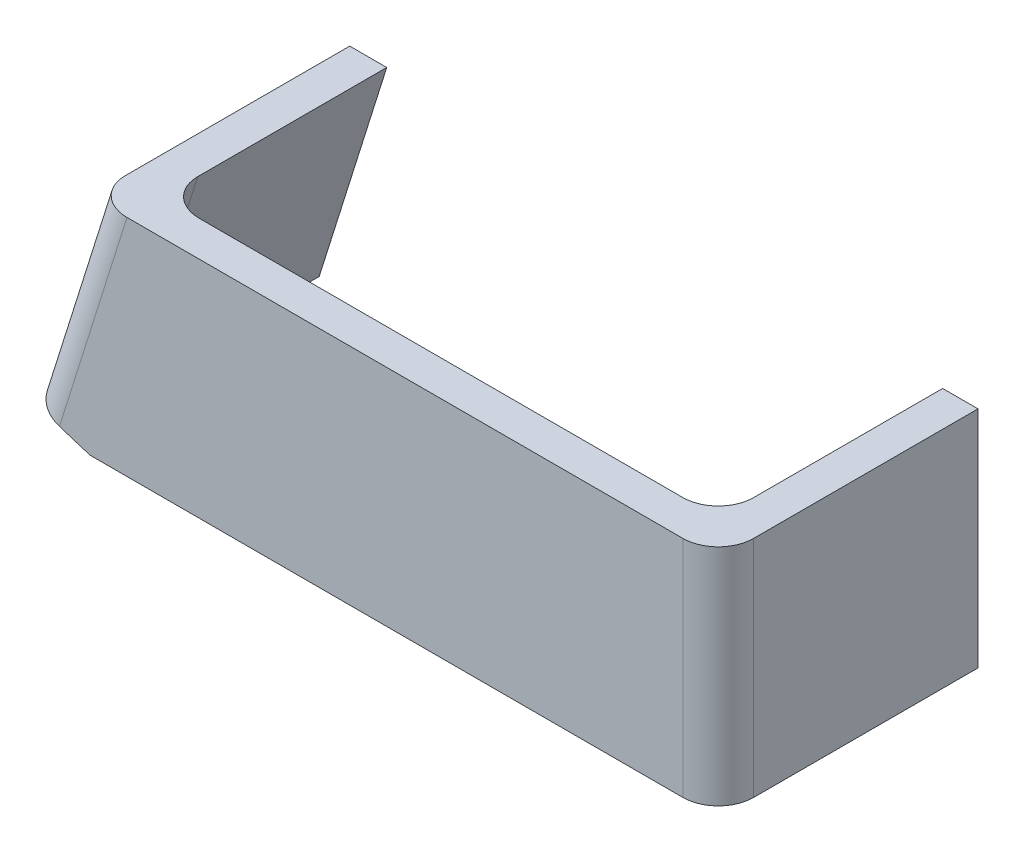
from build123d import *

# Parameters (mm, degrees)
BOSS_EXTRUDE1_DEPTH = 5
BOSS_EXTRUDE2_DEPTH = 31.75
FILLET1_R           = 5


with BuildPart() as part:
    # Sketch1 → Boss-Extrude1 (new body)
    with BuildSketch(Plane.XY):
        Polygon((-44.432958232964275, 15.875000000000018), (44.46704176703572, 15.875000000000021), (44.467041767035624, -15.874999999999979), (-44.43295823296417, -15.875000000000448), (-53.51922912646058, -13.017500000000476), align=None)
    extrude(amount=BOSS_EXTRUDE1_DEPTH)

    # Sketch2 → Boss-Extrude2 (add)
    with BuildSketch(Plane(origin=(0, 0, 0), x_dir=(-1, 0, 0), z_dir=(0, 0, -1))):
        Polygon((-39.467041767035624, 15.875000000000021), (-39.467041767035624, -15.875000000000448), (-44.467041767035624, -15.874999999999979), (-44.46704176703572, 15.875000000000021), align=None)
        Polygon((48.749533119375855, -14.51750000000046), (39.191534049354715, 15.875000000000021), (44.432958232964275, 15.875000000000018), (53.51922912646058, -13.017500000000476), align=None)
    extrude(amount=BOSS_EXTRUDE2_DEPTH)

    # Fillet1
    fillet1_edges = [part.edges().sort_by_distance(p)[0] for p in [
        (-48.97609367971243, 1.4287499999997717, 5),
        (-43.970533584365285, 0.6787499999997806, 0),
        (39.467041767035624, -2.1316e-13, 0),
        (44.46704176703567, 2.132e-14, 5),
    ]]
    fillet(fillet1_edges, radius=FILLET1_R)


solid = part.part
